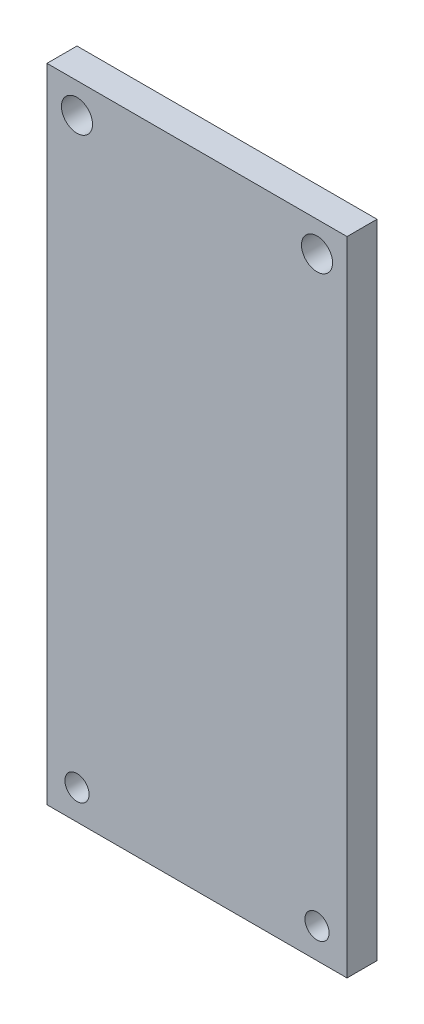
from build123d import *

# Parameters (mm, degrees)
SKETCH_1_W      = 30
SKETCH_1_H      = 64.2
SKETCH_1_R      = 1.554191901
SKETCH_1_R_2    = 1.21166994
EXTRUDE_1_DEPTH = 3


with BuildPart() as part:
    # 草图1 → 凸台-拉伸1 (new body)
    with BuildSketch(Plane.XY):
        with Locations((7.578947368, 16.6)):
            Rectangle(SKETCH_1_W, SKETCH_1_H)
        with Locations((-4.421052632, 45.7)):
            Circle(SKETCH_1_R, mode=Mode.SUBTRACT)
        with Locations((-4.421052632, -12.5)):
            Circle(SKETCH_1_R_2, mode=Mode.SUBTRACT)
        with Locations((19.578947368, -12.5)):
            Circle(SKETCH_1_R_2, mode=Mode.SUBTRACT)
        with Locations((19.578947368, 45.7)):
            Circle(SKETCH_1_R, mode=Mode.SUBTRACT)
    extrude(amount=EXTRUDE_1_DEPTH)


solid = part.part
